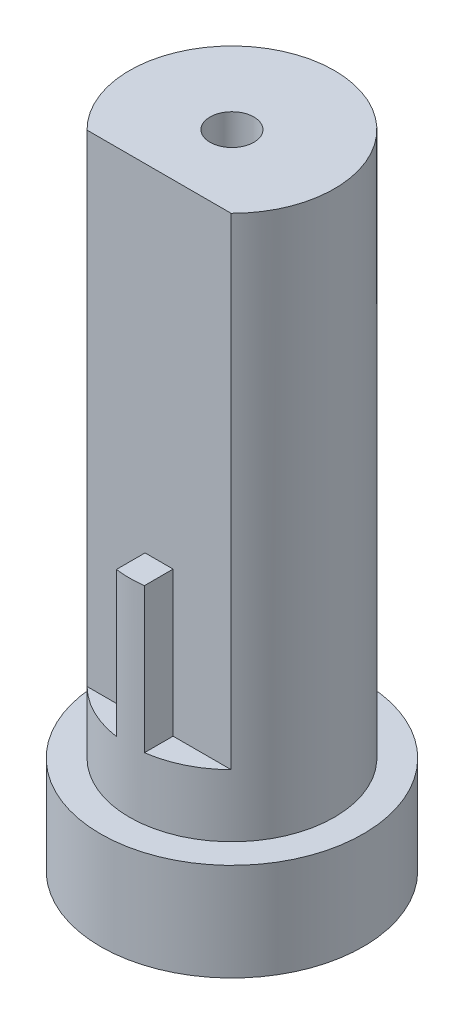
from build123d import *

# Parameters (mm, degrees)
SKETCH1_R           = 9.005
BASE_RING_DEPTH     = 6.69
SKETCH2_R           = 7.025
MAIN_CYLINDER_DEPTH = 44
CUTOUT_PT1_DEPTH    = 33.03
CUTOUT_PT2_DEPTH    = 23.11
SKETCH5_R           = 1.505
TOP_HOLE_DEPTH      = 46.805895363
SKETCH7_R           = 7.875
CUT_EXTRUDE4_DEPTH  = 5.42
SKETCH8_R           = 5.76
CUT_EXTRUDE5_DEPTH  = 8.86
CUT_EXTRUDE6_DEPTH  = 40.88


with BuildPart() as part:
    # Sketch1 → Base Ring (new body)
    with BuildSketch(Plane(origin=(0, 0, 0), x_dir=(1, 0, 0), z_dir=(0, 1, 0))):
        with Locations(Location((0, 0, 0), (0, 0, 270))):
            Circle(SKETCH1_R)
    extrude(amount=BASE_RING_DEPTH)

    # Sketch2 → Main Cylinder (add)
    with BuildSketch(Plane(origin=(0, 0, 0), x_dir=(1, 0, 0), z_dir=(0, 1, 0))):
        with Locations(Location((0, 0, 0), (0, 0, 270))):
            Circle(SKETCH2_R)
    extrude(amount=MAIN_CYLINDER_DEPTH)

    # Sketch3 → Cutout pt1 (cut)
    with BuildSketch(Plane(origin=(0, 44, 0), x_dir=(1, 0, 0), z_dir=(0, 1, 0))):
        with BuildLine():
            Line((-4.939696347, -4.995), (-0.96, -4.995))
            Line((-0.96, -4.995), (-0.96, -6.959096565))
            ThreePointArc((-0.96, -6.959096565), (-3.109022849, -6.299571567), (-4.939696347, -4.995))
        make_face()
        with BuildLine():
            Line((0.96, -4.995), (0.96, -6.959096565))
            ThreePointArc((0.96, -6.959096565), (3.109022849, -6.299571567), (4.939696347, -4.995))
            Line((4.939696347, -4.995), (0.96, -4.995))
        make_face()
    extrude(amount=-CUTOUT_PT1_DEPTH, mode=Mode.SUBTRACT)

    # Sketch4 → Cutout pt2 (cut)
    with BuildSketch(Plane(origin=(0, 44, 0), x_dir=(1, 0, 0), z_dir=(0, 1, 0))):
        with BuildLine():
            Line((-0.96, -4.995), (0.96, -4.995))
            Line((0.96, -4.995), (0.96, -6.959096565))
            ThreePointArc((0.96, -6.959096565), (0, -7.025), (-0.96, -6.959096565))
            Line((-0.96, -6.959096565), (-0.96, -4.995))
        make_face()
    extrude(amount=-CUTOUT_PT2_DEPTH, mode=Mode.SUBTRACT)

    # Sketch5 → Top Hole (cut, through all)
    with BuildSketch(Plane(origin=(0, 44, 0), x_dir=(1, 0, 0), z_dir=(0, 1, 0))):
        with Locations(Location((0, 0, 0), (0, 0, 270))):
            Circle(SKETCH5_R)
    extrude(amount=-TOP_HOLE_DEPTH, mode=Mode.SUBTRACT)

    # Sketch7 → Cut-Extrude4 (cut)
    with BuildSketch(Plane(origin=(0, 0, 0), x_dir=(1, 0, 0), z_dir=(0, 1, 0))):
        with Locations(Location((0, 0, 0), (0, 0, 270))):
            Circle(SKETCH7_R)
    extrude(amount=CUT_EXTRUDE4_DEPTH, mode=Mode.SUBTRACT)

    # Sketch8 → Cut-Extrude5 (cut)
    with BuildSketch(Plane(origin=(0, 0, 0), x_dir=(1, 0, 0), z_dir=(0, 1, 0))):
        with Locations(Location((0, 0, 0), (0, 0, 270))):
            Circle(SKETCH8_R)
    extrude(amount=CUT_EXTRUDE5_DEPTH, mode=Mode.SUBTRACT)

    # Sketch9 → Cut-Extrude6 (cut)
    with BuildSketch(Plane(origin=(0, 0, 0), x_dir=(1, 0, 0), z_dir=(0, 1, 0))):
        with BuildLine():
            Line((4.33745317, -3.79), (-4.33745317, -3.79))
            ThreePointArc((-4.33745317, -3.79), (0, 5.76), (4.33745317, -3.79))
        make_face()
    extrude(amount=CUT_EXTRUDE6_DEPTH, mode=Mode.SUBTRACT)


solid = part.part
